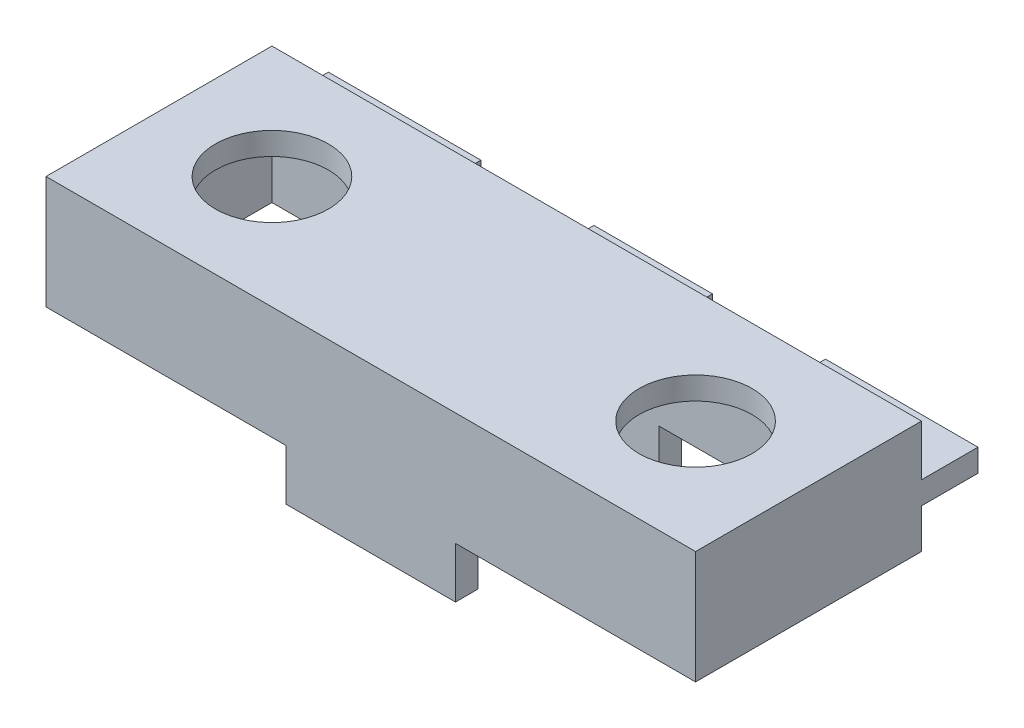
from build123d import *

# Parameters (mm, degrees)
SKETCH3_W           = 146.05
SKETCH3_H           = 50.8
BOSS_EXTRUDE1_DEPTH = 25.4
SHELL1_T            = -5.08
SKETCH4_R           = 12.7
CUT_EXTRUDE1_DEPTH  = 6.35
SKETCH5_W           = 19.05
SKETCH5_H           = 5.08
BOSS_EXTRUDE2_DEPTH = 11.43
SKETCH6_W           = 34.29
SKETCH6_H           = 5.08
SKETCH6_W_2         = 26.67
BOSS_EXTRUDE3_DEPTH = 12.7


with BuildPart() as part:
    # Sketch3 → Boss-Extrude1 (new body)
    with BuildSketch(Plane(origin=(0, 0, 0), x_dir=(1, 0, 0), z_dir=(0, 1, 0))):
        with Locations((73.025, 25.4)):
            Rectangle(SKETCH3_W, SKETCH3_H)
    extrude(amount=-BOSS_EXTRUDE1_DEPTH)

    # Shell1
    shell1_openings = [part.faces().sort_by_distance(p)[0] for p in [
        (73.025, -25.4, -25.4),
    ]]
    offset(amount=SHELL1_T, openings=shell1_openings, kind=Kind.INTERSECTION)

    # Sketch4 → Cut-Extrude1 (cut)
    with BuildSketch(Plane(origin=(0, 0, 0), x_dir=(1, 0, 0), z_dir=(0, 1, 0))):
        with Locations(Location((25.4, 25.4, 0), (0, 0, 270))):  # turned: the seam where the file's is
            Circle(SKETCH4_R)
        with Locations(Location((120.65, 25.4, 0), (0, 0, 270))):  # turned: the seam where the file's is
            Circle(SKETCH4_R)
    extrude(amount=-CUT_EXTRUDE1_DEPTH, mode=Mode.SUBTRACT)

    # Sketch5 → Boss-Extrude2 (add)
    with BuildSketch(Plane.XZ.offset(25.4)):
        with Locations((82.55, -2.54)):
            Rectangle(SKETCH5_W, SKETCH5_H)
        with Locations((63.5, -2.54)):
            Rectangle(SKETCH5_W, SKETCH5_H)
        with Locations((82.55, -48.26)):
            Rectangle(SKETCH5_W, SKETCH5_H)
        with Locations((63.5, -48.26)):
            Rectangle(SKETCH5_W, SKETCH5_H)
    extrude(amount=BOSS_EXTRUDE2_DEPTH)

    # Sketch6 → Boss-Extrude3 (add)
    with BuildSketch(Plane(origin=(0, 0, -50.8), x_dir=(-1, 0, 0), z_dir=(0, 0, -1))):
        with Locations((-128.905, -13.97)):
            Rectangle(SKETCH6_W, SKETCH6_H)
        with Locations((-73.025, -13.97)):
            Rectangle(SKETCH6_W_2, SKETCH6_H)
        with Locations((-17.145, -13.97)):
            Rectangle(SKETCH6_W, SKETCH6_H)
    extrude(amount=BOSS_EXTRUDE3_DEPTH)


solid = part.part
